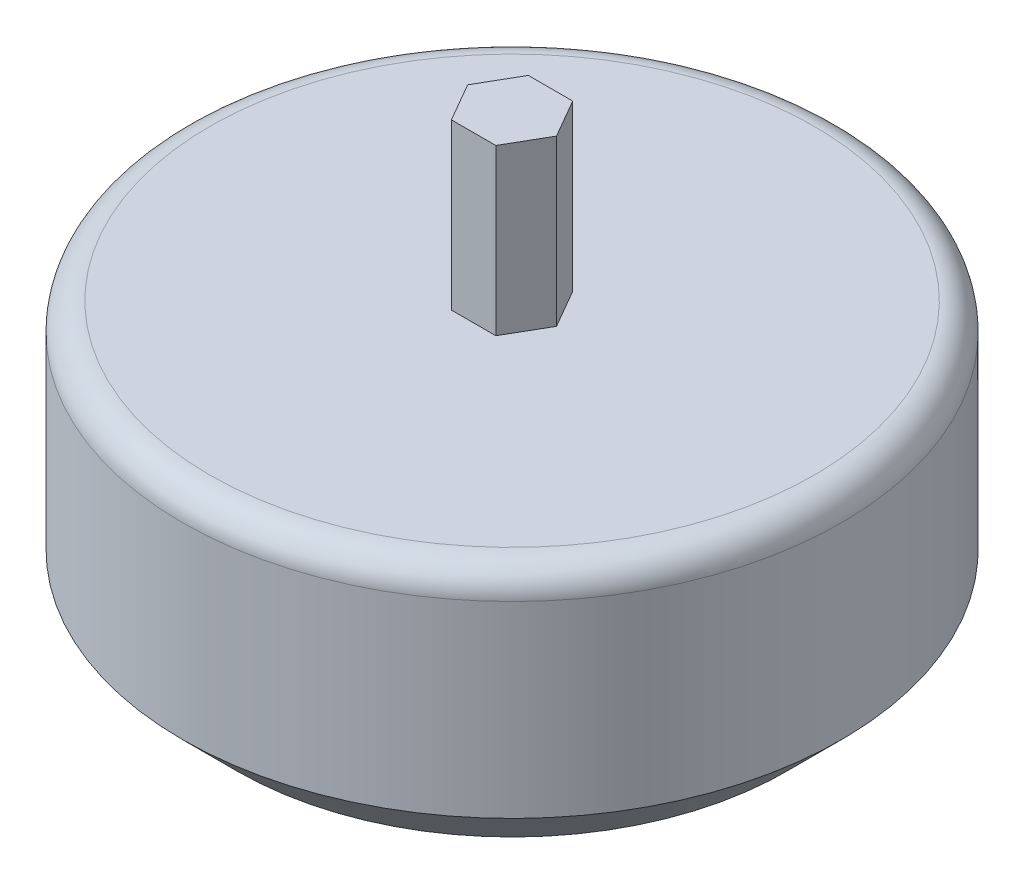
from build123d import *

# Parameters (mm, degrees)
SKETCH1_R                       = 60
BOSS_EXTRUDE1_DEPTH             = 49.2
BOSS_EXTRUDE3_DEPTH             = 30
FILLET1_R                       = 5
TAP_DRILL_FOR_M5X0_8_TAP1_D     = 4.2
TAP_DRILL_FOR_M5X0_8_TAP1_DEPTH = 5
TAP_DRILL_FOR_M5X0_8_TAP1_TIP   = 1.2618073
CHAMFER1_SIZE                   = 10


with BuildPart() as part:
    # Sketch1 → Boss-Extrude1 (new body)
    with BuildSketch(Plane(origin=(0, 0, 0), x_dir=(1, 0, 0), z_dir=(0, 1, 0))):
        Circle(SKETCH1_R)
    extrude(amount=BOSS_EXTRUDE1_DEPTH)

    # Sketch2 → Boss-Extrude3 (add)
    with BuildSketch(Plane(origin=(0, 49.2, 0), x_dir=(1, 0, 0), z_dir=(0, 1, 0))):
        Polygon((-4.041451884, 7), (-8.082903769, 0), (-4.041451884, -7), (4.041451884, -7), (8.082903769, 0), (4.041451884, 7), align=None)
    extrude(amount=BOSS_EXTRUDE3_DEPTH)

    # Fillet1
    fillet1_edges = [part.edges().sort_by_distance(p)[0] for p in [
        (-60, 49.2, 0),
    ]]
    fillet(fillet1_edges, radius=FILLET1_R)

    # Tap Drill for M5x0.8 Tap1
    with Locations(Plane(origin=(0, 0, 0), x_dir=(-1, 0, 0), z_dir=(0, -1, 0))):
        with Locations((-18, 31.176914536), (18, 31.176914536), (18, -31.176914536), (-18, -31.176914536)):
            Hole(TAP_DRILL_FOR_M5X0_8_TAP1_D / 2, depth=TAP_DRILL_FOR_M5X0_8_TAP1_DEPTH)
            with Locations((0, 0, -(TAP_DRILL_FOR_M5X0_8_TAP1_DEPTH + TAP_DRILL_FOR_M5X0_8_TAP1_TIP / 2))):  # 118° drill point
                Cone(0, TAP_DRILL_FOR_M5X0_8_TAP1_D / 2, TAP_DRILL_FOR_M5X0_8_TAP1_TIP, mode=Mode.SUBTRACT)

    # Chamfer1
    chamfer1_edges = [part.edges().sort_by_distance(p)[0] for p in [
        (-60, 0, 0),
    ]]
    chamfer(chamfer1_edges, length=CHAMFER1_SIZE)


solid = part.part
